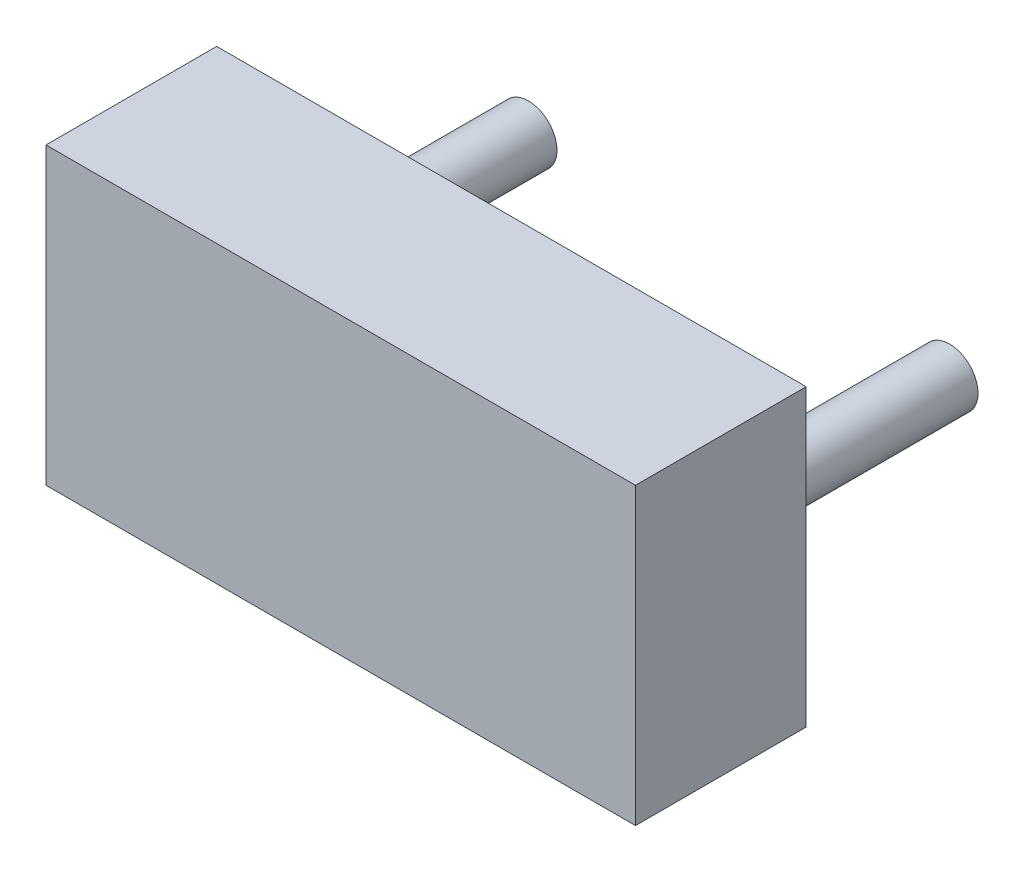
from build123d import *

# Parameters (mm, degrees)
SKETCH1_W               = 5.18
SKETCH1_H               = 2.59
COMPONENT_OUTLINE_DEPTH = 1.5
SKETCH2_R               = 0.25
EXTRUDE_1_DEPTH         = 2
SKETCH3_R               = 0.25
EXTRUDE_2_DEPTH         = 2


with BuildPart() as part:
    # Sketch1 → Component_Outline (new body)
    with BuildSketch(Plane.XY):
        Rectangle(SKETCH1_W, SKETCH1_H)
    extrude(amount=COMPONENT_OUTLINE_DEPTH)


with BuildPart() as body_2:
    # Sketch2 → Extrude 1 (new body)
    with BuildSketch(Plane.XY):
        with Locations((-1.85, 0)):
            Circle(SKETCH2_R)
    extrude(amount=-EXTRUDE_1_DEPTH)


with BuildPart() as body_3:
    # Sketch3 → Extrude 2 (new body)
    with BuildSketch(Plane.XY):
        with Locations((1.85, 0)):
            Circle(SKETCH3_R)
    extrude(amount=-EXTRUDE_2_DEPTH)


solid = Compound([part.part, body_2.part, body_3.part])
